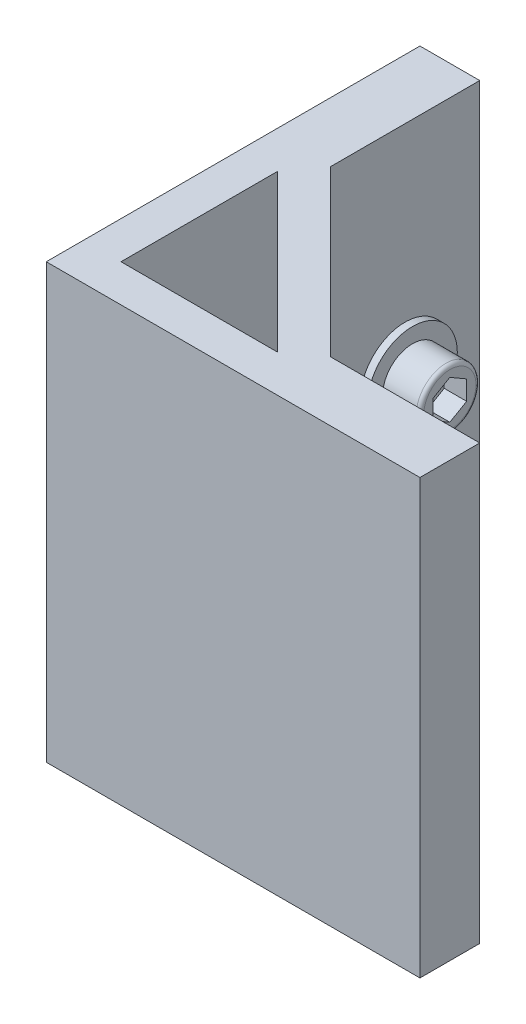
from build123d import *

# Parameters (mm, degrees)
BOSS_EXTRUDE1_DEPTH = 58
SKETCH2_R           = 6
BOSS_EXTRUDE2_DEPTH = 1
SKETCH3_R           = 4
BOSS_EXTRUDE3_DEPTH = 5
CUT_EXTRUDE1_DEPTH  = 3
FILLET1_R           = 0.5


with BuildPart() as part:
    # Sketch1 → Boss-Extrude1 (new body)
    with BuildSketch(Plane(origin=(0, 0, 0), x_dir=(1, 0, 0), z_dir=(0, 1, 0))):
        Polygon((0, 50), (0, 0), (50, 0), (50, 8), (30, 8), (8, 30), (8, 50), align=None)
        Polygon((5, 25.928932188), (25.928932188, 5), (5, 5), align=None, mode=Mode.SUBTRACT)
    extrude(amount=BOSS_EXTRUDE1_DEPTH)

    # Sketch2 → Boss-Extrude2 (add)
    with BuildSketch(Plane(origin=(8, 0, 0), x_dir=(0, 0, -1), z_dir=(1, 0, 0))):
        with Locations((40, 29)):
            Circle(SKETCH2_R)
    extrude(amount=BOSS_EXTRUDE2_DEPTH)

    # Sketch3 → Boss-Extrude3 (add)
    with BuildSketch(Plane(origin=(9, 0, 0), x_dir=(0, 0, -1), z_dir=(1, 0, 0))):
        with Locations((40, 29)):
            Circle(SKETCH3_R)
    extrude(amount=BOSS_EXTRUDE3_DEPTH)

    # Sketch4 → Cut-Extrude1 (cut)
    with BuildSketch(Plane(origin=(14, 0, 0), x_dir=(0, 0, -1), z_dir=(1, 0, 0))):
        Polygon((40, 26.401923789), (42.25, 27.700961894), (42.25, 30.299038106), (40, 31.598076211), (37.75, 30.299038106), (37.75, 27.700961894), align=None)
    extrude(amount=-CUT_EXTRUDE1_DEPTH, mode=Mode.SUBTRACT)

    # Fillet1
    fillet1_edges = [part.edges().sort_by_distance(p)[0] for p in [
        (14, 29, -36),
    ]]
    fillet(fillet1_edges, radius=FILLET1_R)


solid = part.part
